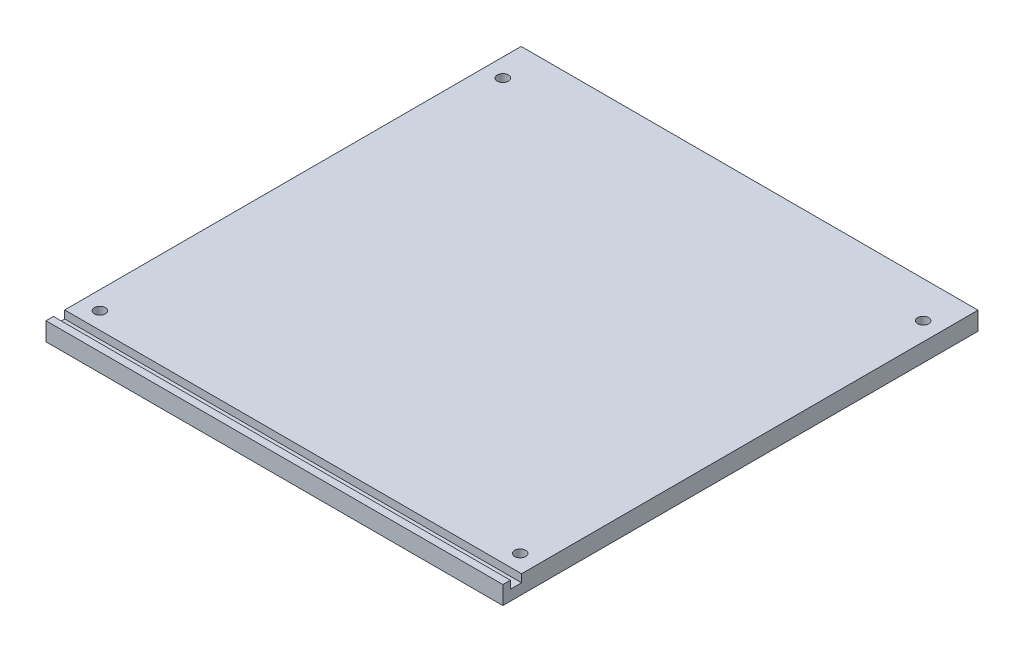
from build123d import *

# Parameters (mm, degrees)
CROQUIS1_W              = 250
CROQUIS1_H              = 260
SALIENTE_EXTRUIR1_DEPTH = 10
CORTAR_EXTRUIR1_REACH   = 252
CROQUIS4_W              = 6.138345694
CROQUIS4_H              = 4.301035896
CORTAR_EXTRUIR2_REACH   = 12
CROQUIS5_R              = 3


with BuildPart() as part:
    # Croquis1 → Saliente-Extruir1 (new body)
    with BuildSketch(Plane(origin=(0, 0, 0), x_dir=(1, 0, 0), z_dir=(0, 1, 0))):
        Rectangle(CROQUIS1_W, CROQUIS1_H)
    extrude(amount=SALIENTE_EXTRUIR1_DEPTH)

    # Croquis4 → Cortar-Extruir1 (cut, up to next)
    with BuildSketch(Plane.ZY.offset(125), mode=Mode.PRIVATE) as cortar_extruir1_sk1:
        with Locations((122.851537289, 7.849482052)):
            Rectangle(CROQUIS4_W, CROQUIS4_H)
    cortar_extruir1_tool1 = extrude(cortar_extruir1_sk1.sketch, amount=-CORTAR_EXTRUIR1_REACH, mode=Mode.PRIVATE) & part.part
    add(cortar_extruir1_tool1.solids().sort_by_distance((-125, 7.849482, 122.851537))[0], mode=Mode.SUBTRACT)

    # Croquis5 → Cortar-Extruir2 (cut, up to next)
    with BuildSketch(Plane.XZ, mode=Mode.PRIVATE) as cortar_extruir2_sk1:
        with Locations((-115, 110.530243228)):
            Circle(CROQUIS5_R)
    cortar_extruir2_tool1 = extrude(cortar_extruir2_sk1.sketch, amount=-CORTAR_EXTRUIR2_REACH, mode=Mode.PRIVATE) & part.part
    add(cortar_extruir2_tool1.solids().sort_by_distance((-115, 0, 110.530243))[0], mode=Mode.SUBTRACT)
    # Croquis5 → Cortar-Extruir2 (cut, up to next)
    with BuildSketch(Plane.XZ, mode=Mode.PRIVATE) as cortar_extruir2_sk2:
        with Locations((115, 110.530243228)):
            Circle(CROQUIS5_R)
    cortar_extruir2_tool2 = extrude(cortar_extruir2_sk2.sketch, amount=-CORTAR_EXTRUIR2_REACH, mode=Mode.PRIVATE) & part.part
    add(cortar_extruir2_tool2.solids().sort_by_distance((115, 0, 110.530243))[0], mode=Mode.SUBTRACT)
    # Croquis5 → Cortar-Extruir2 (cut, up to next)
    with BuildSketch(Plane.XZ, mode=Mode.PRIVATE) as cortar_extruir2_sk3:
        with Locations((-115, -110)):
            Circle(CROQUIS5_R)
    cortar_extruir2_tool3 = extrude(cortar_extruir2_sk3.sketch, amount=-CORTAR_EXTRUIR2_REACH, mode=Mode.PRIVATE) & part.part
    add(cortar_extruir2_tool3.solids().sort_by_distance((-115, 0, -110))[0], mode=Mode.SUBTRACT)
    # Croquis5 → Cortar-Extruir2 (cut, up to next)
    with BuildSketch(Plane.XZ, mode=Mode.PRIVATE) as cortar_extruir2_sk4:
        with Locations((115, -110)):
            Circle(CROQUIS5_R)
    cortar_extruir2_tool4 = extrude(cortar_extruir2_sk4.sketch, amount=-CORTAR_EXTRUIR2_REACH, mode=Mode.PRIVATE) & part.part
    add(cortar_extruir2_tool4.solids().sort_by_distance((115, 0, -110))[0], mode=Mode.SUBTRACT)


solid = part.part
